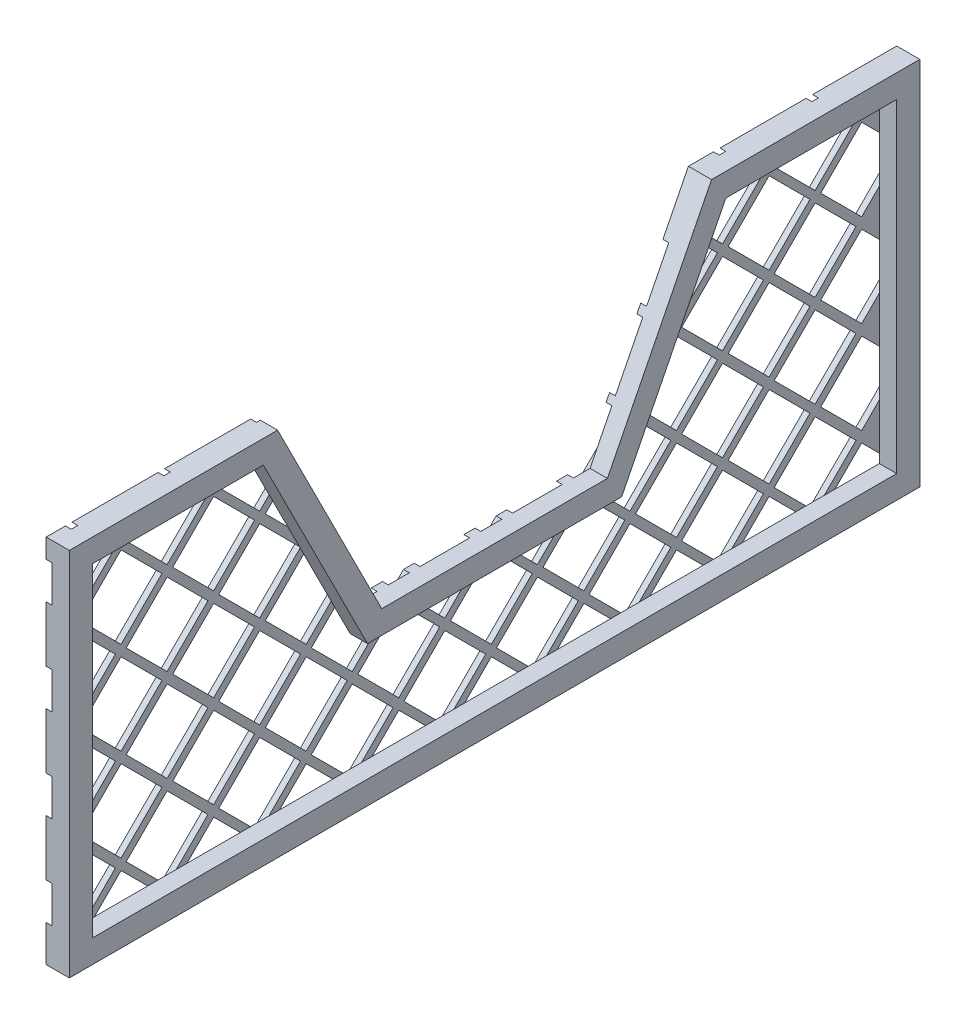
from build123d import *

# Parameters (mm, degrees)
BOSS_EXTRUDE1_DEPTH = 12.7
BOSS_EXTRUDE4_DEPTH = 3.175
CUT_EXTRUDE2_DEPTH  = 3.175


with BuildPart() as part:
    # Sketch1 → Boss-Extrude1 (new body)
    with BuildSketch(Plane(origin=(0, 0, 0), x_dir=(0, 0, -1), z_dir=(1, 0, 0))):
        Polygon((-163.889238953, 74.360474632), (-49.589238953, 74.360474632), (7.560761047, -39.05415185), (131.385761047, -39.05415185), (188.535761047, 74.360474632), (302.835761047, 74.360474632), (302.835761047, -128.839525368), (-163.889238953, -128.839525368), align=None)
        Polygon((290.135761047, 61.660474632), (290.135761047, -116.139525368), (-151.189238953, -116.139525368), (-151.189238953, 61.660474632), (-57.410937331, 61.660474632), (-0.260937331, -51.75415185), (139.207459426, -51.75415185), (196.357459426, 61.660474632), align=None, mode=Mode.SUBTRACT)
    extrude(amount=BOSS_EXTRUDE1_DEPTH)

    # Sketch4 → Boss-Extrude4 (add)
    with BuildSketch(Plane.ZY):
        Polygon((-290.135761047, 61.660474632), (-196.357459426, 61.660474632), (-139.207459426, -51.75415185), (0.260937331, -51.75415185), (57.410937331, 61.660474632), (151.189238953, 61.660474632), (151.189238953, -116.139525368), (-290.135761047, -116.139525368), align=None)
    extrude(amount=-BOSS_EXTRUDE4_DEPTH)

    # Sketch6 → Cut-Extrude2 (cut)
    with BuildSketch(Plane(origin=(3.175, 0, 0), x_dir=(0, 0, -1), z_dir=(1, 0, 0))):
        Polygon((-148.417221804, 28.435553265), (-125.966581502, 50.886193567), (-103.515941199, 28.435553265), (-125.966581502, 5.984912962), align=None)
        Polygon((-151.510335077, 76.142439992), (-129.059694774, 53.69179969), (-151.510335077, 31.241159387), (-173.96097538, 53.69179969), align=None)
        Polygon((-97.617221804, 28.435553265), (-75.166581502, 50.886193567), (-52.715941199, 28.435553265), (-75.166581502, 5.984912962), align=None)
        Polygon((-100.710335077, 31.241159387), (-123.16097538, 53.69179969), (-100.710335077, 76.142439992), (-78.259694774, 53.69179969), align=None)
        Polygon((-46.817221804, 28.435553265), (-24.366581502, 50.886193567), (-1.915941199, 28.435553265), (-24.366581502, 5.984912962), align=None)
        Polygon((-49.910335077, 31.241159387), (-72.36097538, 53.69179969), (-49.910335077, 76.142439992), (-27.459694774, 53.69179969), align=None)
        Polygon((3.982778196, 28.435553265), (26.433418498, 50.886193567), (48.884058801, 28.435553265), (26.433418498, 5.984912962), align=None)
        Polygon((0.889664923, 31.241159387), (-21.56097538, 53.69179969), (0.889664923, 76.142439992), (23.340305226, 53.69179969), align=None)
        Polygon((54.782778196, 28.435553265), (77.233418498, 50.886193567), (99.684058801, 28.435553265), (77.233418498, 5.984912962), align=None)
        Polygon((51.689664923, 31.241159387), (29.23902462, 53.69179969), (51.689664923, 76.142439992), (74.140305226, 53.69179969), align=None)
        Polygon((105.582778196, 28.435553265), (128.033418498, 50.886193567), (150.484058801, 28.435553265), (128.033418498, 5.984912962), align=None)
        Polygon((102.489664923, 31.241159387), (80.03902462, 53.69179969), (102.489664923, 76.142439992), (124.940305226, 53.69179969), align=None)
        Polygon((156.382778196, 28.435553265), (178.833418498, 50.886193567), (201.284058801, 28.435553265), (178.833418498, 5.984912962), align=None)
        Polygon((153.289664923, 31.241159387), (130.83902462, 53.69179969), (153.289664923, 76.142439992), (175.740305226, 53.69179969), align=None)
        Polygon((207.182778196, 28.435553265), (229.633418498, 50.886193567), (252.084058801, 28.435553265), (229.633418498, 5.984912962), align=None)
        Polygon((204.089664923, 31.241159387), (181.63902462, 53.69179969), (204.089664923, 76.142439992), (226.540305226, 53.69179969), align=None)
        Polygon((257.982778196, 28.435553265), (280.433418498, 50.886193567), (302.884058801, 28.435553265), (280.433418498, 5.984912962), align=None)
        Polygon((254.889664923, 31.241159387), (232.43902462, 53.69179969), (254.889664923, 76.142439992), (277.340305226, 53.69179969), align=None)
        Polygon((-97.617221804, -22.364446735), (-75.166581502, 0.086193567), (-52.715941199, -22.364446735), (-75.166581502, -44.815087038), align=None)
        Polygon((-100.710335077, -19.558840613), (-123.16097538, 2.89179969), (-100.710335077, 25.342439992), (-78.259694774, 2.89179969), align=None)
        Polygon((-46.817221804, -22.364446735), (-24.366581502, 0.086193567), (-1.915941199, -22.364446735), (-24.366581502, -44.815087038), align=None)
        Polygon((-49.910335077, -19.558840613), (-72.36097538, 2.89179969), (-49.910335077, 25.342439992), (-27.459694774, 2.89179969), align=None)
        Polygon((3.982778196, -22.364446735), (26.433418498, 0.086193567), (48.884058801, -22.364446735), (26.433418498, -44.815087038), align=None)
        Polygon((0.889664923, -19.558840613), (-21.56097538, 2.89179969), (0.889664923, 25.342439992), (23.340305226, 2.89179969), align=None)
        Polygon((54.782778196, -22.364446735), (77.233418498, 0.086193567), (99.684058801, -22.364446735), (77.233418498, -44.815087038), align=None)
        Polygon((51.689664923, -19.558840613), (29.23902462, 2.89179969), (51.689664923, 25.342439992), (74.140305226, 2.89179969), align=None)
        Polygon((105.582778196, -22.364446735), (128.033418498, 0.086193567), (150.484058801, -22.364446735), (128.033418498, -44.815087038), align=None)
        Polygon((102.489664923, -19.558840613), (80.03902462, 2.89179969), (102.489664923, 25.342439992), (124.940305226, 2.89179969), align=None)
        Polygon((156.382778196, -22.364446735), (178.833418498, 0.086193567), (201.284058801, -22.364446735), (178.833418498, -44.815087038), align=None)
        Polygon((153.289664923, -19.558840613), (130.83902462, 2.89179969), (153.289664923, 25.342439992), (175.740305226, 2.89179969), align=None)
        Polygon((207.182778196, -22.364446735), (229.633418498, 0.086193567), (252.084058801, -22.364446735), (229.633418498, -44.815087038), align=None)
        Polygon((204.089664923, -19.558840613), (181.63902462, 2.89179969), (204.089664923, 25.342439992), (226.540305226, 2.89179969), align=None)
        Polygon((257.982778196, -22.364446735), (280.433418498, 0.086193567), (302.884058801, -22.364446735), (280.433418498, -44.815087038), align=None)
        Polygon((254.889664923, -19.558840613), (232.43902462, 2.89179969), (254.889664923, 25.342439992), (277.340305226, 2.89179969), align=None)
        Polygon((-97.617221804, -73.164446735), (-75.166581502, -50.713806433), (-52.715941199, -73.164446735), (-75.166581502, -95.615087038), align=None)
        Polygon((-100.710335077, -70.358840613), (-123.16097538, -47.90820031), (-100.710335077, -25.457560008), (-78.259694774, -47.90820031), align=None)
        Polygon((-46.817221804, -73.164446735), (-24.366581502, -50.713806433), (-1.915941199, -73.164446735), (-24.366581502, -95.615087038), align=None)
        Polygon((-49.910335077, -70.358840613), (-72.36097538, -47.90820031), (-49.910335077, -25.457560008), (-27.459694774, -47.90820031), align=None)
        Polygon((3.982778196, -73.164446735), (26.433418498, -50.713806433), (48.884058801, -73.164446735), (26.433418498, -95.615087038), align=None)
        Polygon((0.889664923, -70.358840613), (-21.56097538, -47.90820031), (0.889664923, -25.457560008), (23.340305226, -47.90820031), align=None)
        Polygon((54.782778196, -73.164446735), (77.233418498, -50.713806433), (99.684058801, -73.164446735), (77.233418498, -95.615087038), align=None)
        Polygon((51.689664923, -70.358840613), (29.23902462, -47.90820031), (51.689664923, -25.457560008), (74.140305226, -47.90820031), align=None)
        Polygon((105.582778196, -73.164446735), (128.033418498, -50.713806433), (150.484058801, -73.164446735), (128.033418498, -95.615087038), align=None)
        Polygon((102.489664923, -70.358840613), (80.03902462, -47.90820031), (102.489664923, -25.457560008), (124.940305226, -47.90820031), align=None)
        Polygon((156.382778196, -73.164446735), (178.833418498, -50.713806433), (201.284058801, -73.164446735), (178.833418498, -95.615087038), align=None)
        Polygon((153.289664923, -70.358840613), (130.83902462, -47.90820031), (153.289664923, -25.457560008), (175.740305226, -47.90820031), align=None)
        Polygon((207.182778196, -73.164446735), (229.633418498, -50.713806433), (252.084058801, -73.164446735), (229.633418498, -95.615087038), align=None)
        Polygon((204.089664923, -70.358840613), (181.63902462, -47.90820031), (204.089664923, -25.457560008), (226.540305226, -47.90820031), align=None)
        Polygon((257.982778196, -73.164446735), (280.433418498, -50.713806433), (302.884058801, -73.164446735), (280.433418498, -95.615087038), align=None)
        Polygon((254.889664923, -70.358840613), (232.43902462, -47.90820031), (254.889664923, -25.457560008), (277.340305226, -47.90820031), align=None)
        Polygon((-97.617221804, -123.964446735), (-75.166581502, -101.513806433), (-52.715941199, -123.964446735), (-75.166581502, -146.415087038), align=None)
        Polygon((-100.710335077, -121.158840613), (-123.16097538, -98.70820031), (-100.710335077, -76.257560008), (-78.259694774, -98.70820031), align=None)
        Polygon((-46.817221804, -123.964446735), (-24.366581502, -101.513806433), (-1.915941199, -123.964446735), (-24.366581502, -146.415087038), align=None)
        Polygon((-49.910335077, -121.158840613), (-72.36097538, -98.70820031), (-49.910335077, -76.257560008), (-27.459694774, -98.70820031), align=None)
        Polygon((3.982778196, -123.964446735), (26.433418498, -101.513806433), (48.884058801, -123.964446735), (26.433418498, -146.415087038), align=None)
        Polygon((0.889664923, -121.158840613), (-21.56097538, -98.70820031), (0.889664923, -76.257560008), (23.340305226, -98.70820031), align=None)
        Polygon((54.782778196, -123.964446735), (77.233418498, -101.513806433), (99.684058801, -123.964446735), (77.233418498, -146.415087038), align=None)
        Polygon((51.689664923, -121.158840613), (29.23902462, -98.70820031), (51.689664923, -76.257560008), (74.140305226, -98.70820031), align=None)
        Polygon((105.582778196, -123.964446735), (128.033418498, -101.513806433), (150.484058801, -123.964446735), (128.033418498, -146.415087038), align=None)
        Polygon((102.489664923, -121.158840613), (80.03902462, -98.70820031), (102.489664923, -76.257560008), (124.940305226, -98.70820031), align=None)
        Polygon((156.382778196, -123.964446735), (178.833418498, -101.513806433), (201.284058801, -123.964446735), (178.833418498, -146.415087038), align=None)
        Polygon((153.289664923, -121.158840613), (130.83902462, -98.70820031), (153.289664923, -76.257560008), (175.740305226, -98.70820031), align=None)
        Polygon((207.182778196, -123.964446735), (229.633418498, -101.513806433), (252.084058801, -123.964446735), (229.633418498, -146.415087038), align=None)
        Polygon((204.089664923, -121.158840613), (181.63902462, -98.70820031), (204.089664923, -76.257560008), (226.540305226, -98.70820031), align=None)
        Polygon((257.982778196, -123.964446735), (280.433418498, -101.513806433), (302.884058801, -123.964446735), (280.433418498, -146.415087038), align=None)
        Polygon((254.889664923, -121.158840613), (232.43902462, -98.70820031), (254.889664923, -76.257560008), (277.340305226, -98.70820031), align=None)
        Polygon((-148.417221804, -22.364446735), (-125.966581502, 0.086193567), (-103.515941199, -22.364446735), (-125.966581502, -44.815087038), align=None)
        Polygon((-151.510335077, -19.558840613), (-173.96097538, 2.89179969), (-151.510335077, 25.342439992), (-129.059694774, 2.89179969), align=None)
        Polygon((-148.417221804, -73.164446735), (-125.966581502, -50.713806433), (-103.515941199, -73.164446735), (-125.966581502, -95.615087038), align=None)
        Polygon((-151.510335077, -70.358840613), (-173.96097538, -47.90820031), (-151.510335077, -25.457560008), (-129.059694774, -47.90820031), align=None)
        Polygon((-148.417221804, -123.964446735), (-125.966581502, -101.513806433), (-103.515941199, -123.964446735), (-125.966581502, -146.415087038), align=None)
        Polygon((-151.510335077, -121.158840613), (-173.96097538, -98.70820031), (-151.510335077, -76.257560008), (-129.059694774, -98.70820031), align=None)
    extrude(amount=-CUT_EXTRUDE2_DEPTH, mode=Mode.SUBTRACT)


solid = part.part
